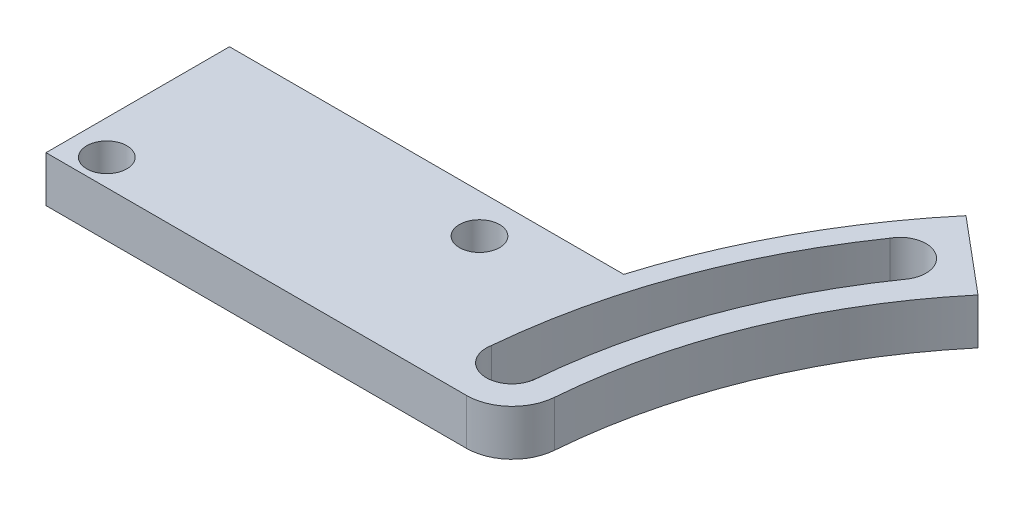
from build123d import *

# Parameters (mm, degrees)
SKETCH1_R           = 55
BOSS_EXTRUDE1_DEPTH = 4
SKETCH6_W           = 87
SKETCH6_H           = 16
BOSS_EXTRUDE2_DEPTH = 4
SKETCH2_R           = 46.5
CUT_EXTRUDE1_DEPTH  = 5
SKETCH3_R           = 2.25
CUT_EXTRUDE2_DEPTH  = 5
CIRPATTERN1_COUNT   = 12
CUT_EXTRUDE3_DEPTH  = 5
SKETCH7_R           = 1.75
CUT_EXTRUDE4_DEPTH  = 5
FILLET1_R           = 4
CUT_EXTRUDE5_DEPTH  = 5


with BuildPart() as part:
    # Sketch1 → Boss-Extrude1 (new body)
    with BuildSketch(Plane(origin=(0, 0, 0), x_dir=(1, 0, 0), z_dir=(0, 1, 0))):
        Circle(SKETCH1_R)
    extrude(amount=BOSS_EXTRUDE1_DEPTH)

    # Sketch6 → Boss-Extrude2 (add)
    with BuildSketch(Plane(origin=(0, 0, 0), x_dir=(1, 0, 0), z_dir=(0, 1, 0))):
        with Locations((-43.5, 8)):
            Rectangle(SKETCH6_W, SKETCH6_H)
    extrude(amount=BOSS_EXTRUDE2_DEPTH)

    # Sketch2 → Cut-Extrude1 (cut, through all)
    with BuildSketch(Plane(origin=(0, 0, 0), x_dir=(1, 0, 0), z_dir=(0, 1, 0))):
        Circle(SKETCH2_R)
    extrude(amount=CUT_EXTRUDE1_DEPTH, mode=Mode.SUBTRACT)

    # Sketch3 → Cut-Extrude2 (cut, through all)
    with BuildSketch(Plane(origin=(0, 0, 0), x_dir=(1, 0, 0), z_dir=(0, 1, 0))):
        with Locations((-50.805929603, 4.44494288)):
            Circle(SKETCH3_R)
    cut_extrude2 = extrude(amount=CUT_EXTRUDE2_DEPTH, mode=Mode.SUBTRACT)

    # CirPattern1: Cut-Extrude2 ×12 about axis
    cirpattern1_axis = Axis((0, 0, 0), (0, 1, 0))
    for i in range(1, CIRPATTERN1_COUNT):
        add(cut_extrude2.rotate(cirpattern1_axis, i * 360 / CIRPATTERN1_COUNT), mode=Mode.SUBTRACT)

    # Sketch4 → Cut-Extrude3 (cut, through all)
    with BuildSketch(Plane(origin=(0, 0, 0), x_dir=(1, 0, 0), z_dir=(0, 1, 0))):
        with BuildLine():
            Line((0, 0), (-62.402274146, 0))
            ThreePointArc((-62.402274146, 0), (58.638956535, -21.342834747), (-47.802915347, 40.111408637))
            Line((-47.802915347, 40.111408637), (0, 0))
        make_face()
    extrude(amount=CUT_EXTRUDE3_DEPTH, mode=Mode.SUBTRACT)

    # Sketch7 → Cut-Extrude4 (cut, through all)
    with BuildSketch(Plane(origin=(0, 0, 0), x_dir=(1, 0, 0), z_dir=(0, 1, 0))):
        with Locations((-61.8, 12.6)):
            Circle(SKETCH7_R)
        with Locations((-84, 2.3)):
            Circle(SKETCH7_R)
    extrude(amount=CUT_EXTRUDE4_DEPTH, mode=Mode.SUBTRACT)

    # Fillet1
    fillet1_edges = [part.edges().sort_by_distance(p)[0] for p in [
        (-46.5, 2, 0),
    ]]
    fillet(fillet1_edges, radius=FILLET1_R)

    # Sketch8 → Cut-Extrude5 (cut, through all)
    with BuildSketch(Plane(origin=(0, 0, 0), x_dir=(1, 0, 0), z_dir=(0, 1, 0))):
        with BuildLine():
            Line((-39.970362944, 27.909363771), (-43.650121746, 30.47876068))
            ThreePointArc((-43.650121746, 30.47876068), (-50.07963309, 18.064283285), (-53.055558124, 4.404058716))
            Line((-53.055558124, 4.404058716), (-48.582909499, 4.032791164))
            ThreePointArc((-48.582909499, 4.032791164), (-45.857858596, 16.541442048), (-39.970362944, 27.909363771))
        make_face()
    extrude(amount=CUT_EXTRUDE5_DEPTH, mode=Mode.SUBTRACT)


solid = part.part
